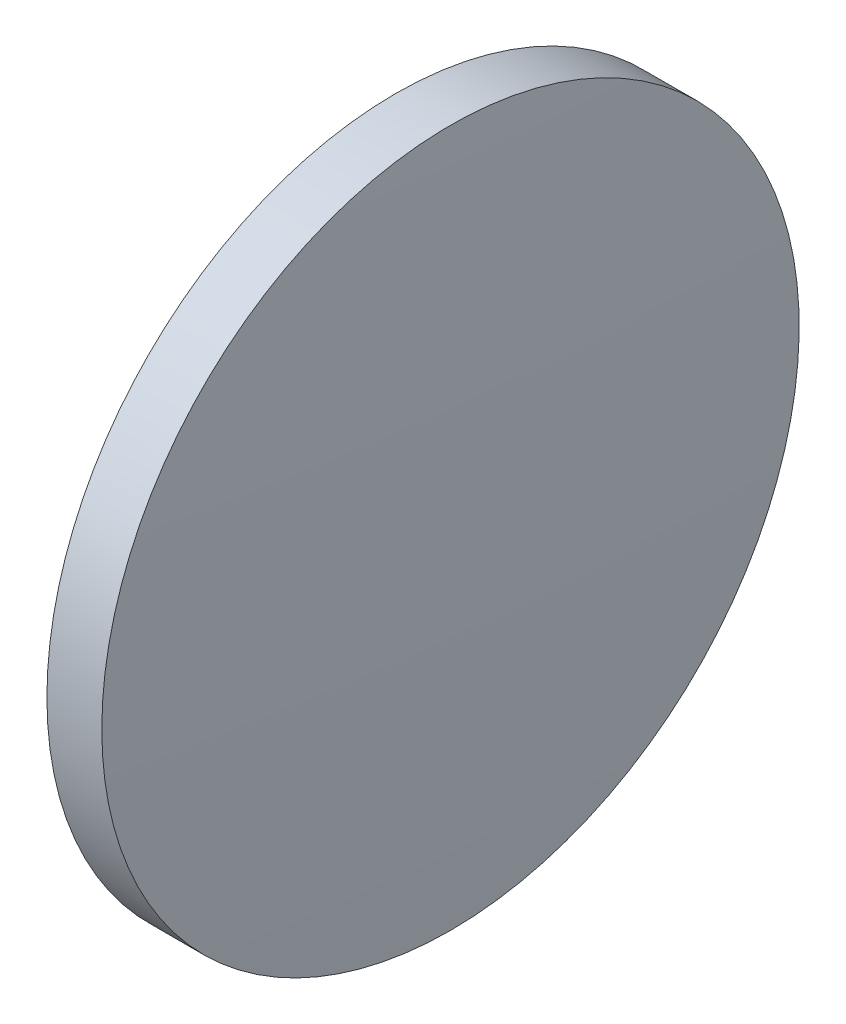
from build123d import *

# Parameters (mm, degrees)
SKETCH_1_ONE_SIDE_W = 1.999342857
SKETCH_1_ONE_SIDE_H = 12.7


with BuildPart() as part:
    # 草图1 one side → 旋转1 (revolve)
    with BuildSketch(Plane.XY, mode=Mode.PRIVATE) as revolve_1_sk:
        with Locations((86.458193775, 54.966113023)):
            Rectangle(SKETCH_1_ONE_SIDE_W, SKETCH_1_ONE_SIDE_H)
        with BuildLine():
            Line((85.158221775, 48.616113023), (85.458522346, 48.616113023))
            Line((85.458522346, 48.616113023), (85.458522346, 61.316113023))
            ThreePointArc((85.458522346, 61.316113023), (85.233307409, 54.96788798), (85.158221775, 48.616113023))
        make_face()
        with BuildLine():
            Line((87.457865203, 48.616113023), (87.758165775, 48.616113023))
            ThreePointArc((87.758165775, 48.616113023), (87.683080141, 54.96788798), (87.457865203, 61.316113023))
            Line((87.457865203, 61.316113023), (87.457865203, 48.616113023))
        make_face()
    revolve(revolve_1_sk.sketch.rotate(Axis((79.305401351, 48.616113023, 0), (1, 0, 0)), 90), axis=Axis((79.305401351, 48.616113023, 0), (1, 0, 0)))  # turned: the seam where the file's is


solid = part.part
